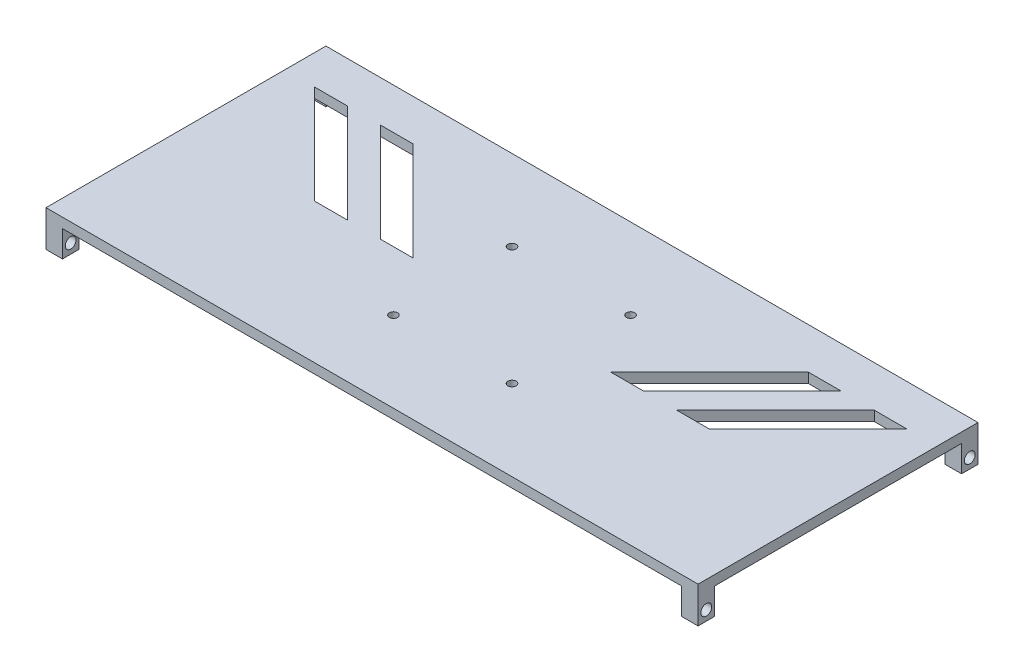
from build123d import *

# Parameters (mm, degrees)
SKETCH_1_W          = 198
SKETCH_1_H          = 85
EXTRUDE_1_DEPTH     = 3
SKETCH_3_W          = 4.997331483
SKETCH_3_H          = 8
SKETCH_3_R          = 1.65
SKETCH_3_W_2        = 5
EXTRUDE_2_DEPTH     = 5
SKETCH_4_W          = 5
SKETCH_4_H          = 8
SKETCH_4_R          = 1.65
EXTRUDE_3_DEPTH     = 5
SKETCH_5_R          = 1.25
CUT_EXTRUDE_1_DEPTH = 10
CUT_EXTRUDE_2_DEPTH = 3


with BuildPart() as part:
    # 草图1 → 凸台-拉伸1 (new body)
    with BuildSketch(Plane(origin=(0, 0, 0), x_dir=(1, 0, 0), z_dir=(0, 1, 0))):
        Rectangle(SKETCH_1_W, SKETCH_1_H)
    extrude(amount=EXTRUDE_1_DEPTH)

    # 草图3 → 凸台-拉伸2 (add)
    with BuildSketch(Plane.ZY.offset(99)):
        with Locations((-40.001334259, -4)):
            Rectangle(SKETCH_3_W, SKETCH_3_H)
        with Locations((-40, -5)):
            Circle(SKETCH_3_R, mode=Mode.SUBTRACT)
        with Locations((40, -4)):
            Rectangle(SKETCH_3_W_2, SKETCH_3_H)
        with Locations((40, -5)):
            Circle(SKETCH_3_R, mode=Mode.SUBTRACT)
    extrude(amount=-EXTRUDE_2_DEPTH)

    # 草图4 → 凸台-拉伸3 (add)
    with BuildSketch(Plane(origin=(99, 0, 0), x_dir=(0, 0, -1), z_dir=(1, 0, 0))):
        with Locations((-40, -4)):
            Rectangle(SKETCH_4_W, SKETCH_4_H)
        with Locations((-40, -5)):
            Circle(SKETCH_4_R, mode=Mode.SUBTRACT)
        with Locations((40, -4)):
            Rectangle(SKETCH_4_W, SKETCH_4_H)
        with Locations((40, -5)):
            Circle(SKETCH_4_R, mode=Mode.SUBTRACT)
    extrude(amount=-EXTRUDE_3_DEPTH)

    # 草图5 → 切除-拉伸1 (cut)
    with BuildSketch(Plane(origin=(0, 3, 0), x_dir=(1, 0, 0), z_dir=(0, 1, 0))):
        with Locations((-18, 18)):
            Circle(SKETCH_5_R)
        with Locations((-18, -18)):
            Circle(SKETCH_5_R)
        with Locations((18, -18)):
            Circle(SKETCH_5_R)
        with Locations((18, 18)):
            Circle(SKETCH_5_R)
    extrude(amount=-CUT_EXTRUDE_1_DEPTH, mode=Mode.SUBTRACT)

    # 草图6 → 切除-拉伸2 (cut)
    with BuildSketch(Plane(origin=(0, 3, 0), x_dir=(1, 0, 0), z_dir=(0, 1, 0))):
        Polygon((60, 30), (70, 30), (40, 0), (30, 0), align=None)
        Polygon((-40, 0), (-30, 0), (-60, 30), (-70, 30), align=None)
        Polygon((-60, 0), (-50, 0), (-80, 30), (-90, 30), align=None)
        Polygon((80, 30), (90, 30), (60, 0), (50, 0), align=None)
    extrude(amount=-CUT_EXTRUDE_2_DEPTH, mode=Mode.SUBTRACT)


solid = part.part
